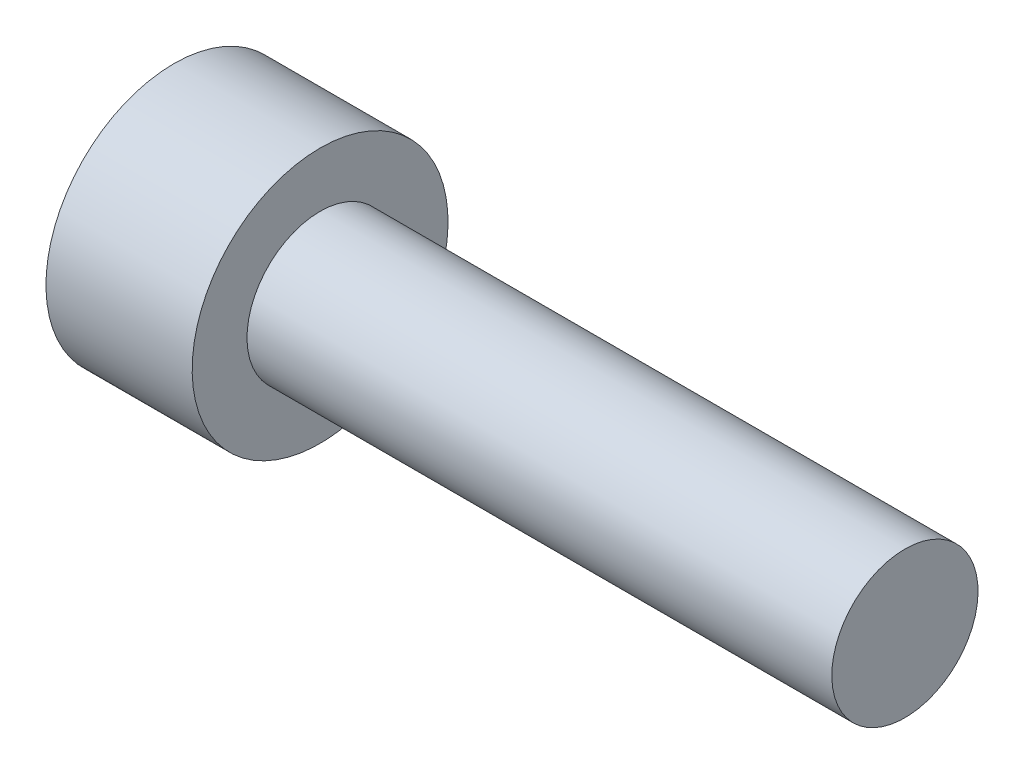
from build123d import *

# Parameters (mm, degrees)
WYTNIJ_WYCI_GNI_CIE1_DEPTH = 2


with BuildPart() as part:
    # Szkic1 → Obrót1 (revolve)
    with BuildSketch(Plane.XY):
        Polygon((0, 0), (0, 3.5), (4, 3.5), (4, 2), (20, 2), (20, 0), align=None)
    revolve(axis=Axis((20, 0, 0), (-1, 0, 0)))

    # Szkic2 → Wytnij-wyciągnięcie1 (cut)
    with BuildSketch(Plane.ZY):
        Polygon((-0.866025404, -1.5), (0.866025404, -1.5), (1.732050808, 0), (0.866025404, 1.5), (-0.866025404, 1.5), (-1.732050808, 0), align=None)
    extrude(amount=-WYTNIJ_WYCI_GNI_CIE1_DEPTH, mode=Mode.SUBTRACT)


solid = part.part
